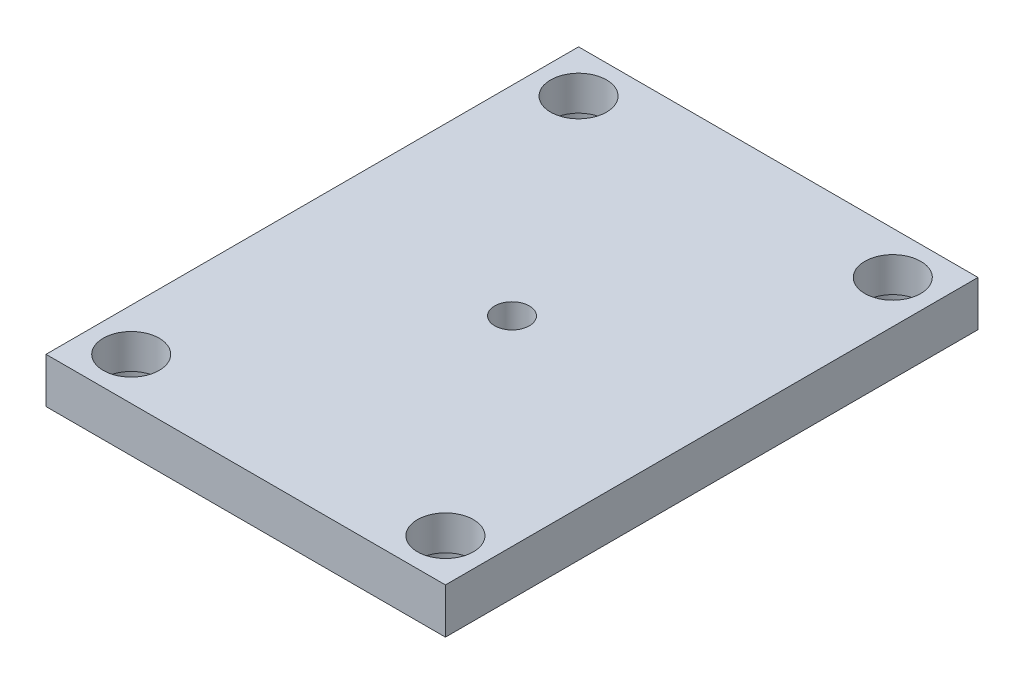
from build123d import *

# Parameters (mm, degrees)
ESBO_O1_W                  = 300
ESBO_O1_H                  = 400
ESBO_O1_R                  = 13
EXTRUS_O1_DEPTH            = 34
FURO_ROSCADO_DE_M161_D     = 14
FURO_ROSCADO_DE_M161_DEPTH = 28
FURO_ROSCADO_DE_M161_TIP   = 4.206024333
FURO1_D                    = 42
FURO1_CBORE_D              = 48
FURO1_CBORE_DEPTH          = 8


with BuildPart() as part:
    # Esboço1 → Extrusão1 (new body)
    with BuildSketch(Plane(origin=(0, 0, 0), x_dir=(1, 0, 0), z_dir=(0, 1, 0))):
        Rectangle(ESBO_O1_W, ESBO_O1_H)
        with Locations(Location((0, 0, 0), (0, 0, 270))):  # turned: the seam where the file's is
            Circle(ESBO_O1_R, mode=Mode.SUBTRACT)
    extrude(amount=EXTRUS_O1_DEPTH)

    # Furo roscado de M161
    with Locations(Plane.XZ):
        with Locations((-118, 119), (118, 119), (-118, -119), (118, -119)):
            Hole(FURO_ROSCADO_DE_M161_D / 2, depth=FURO_ROSCADO_DE_M161_DEPTH)
            with Locations((0, 0, -(FURO_ROSCADO_DE_M161_DEPTH + FURO_ROSCADO_DE_M161_TIP / 2))):  # 118° drill point
                Cone(0, FURO_ROSCADO_DE_M161_D / 2, FURO_ROSCADO_DE_M161_TIP, mode=Mode.SUBTRACT)

    # Furo1 (through all)
    with Locations(Plane.XZ):
        with Locations((118, 168), (118, -168), (-118, -168), (-118, 168)):
            CounterBoreHole(FURO1_D / 2, FURO1_CBORE_D / 2, FURO1_CBORE_DEPTH)


solid = part.part
